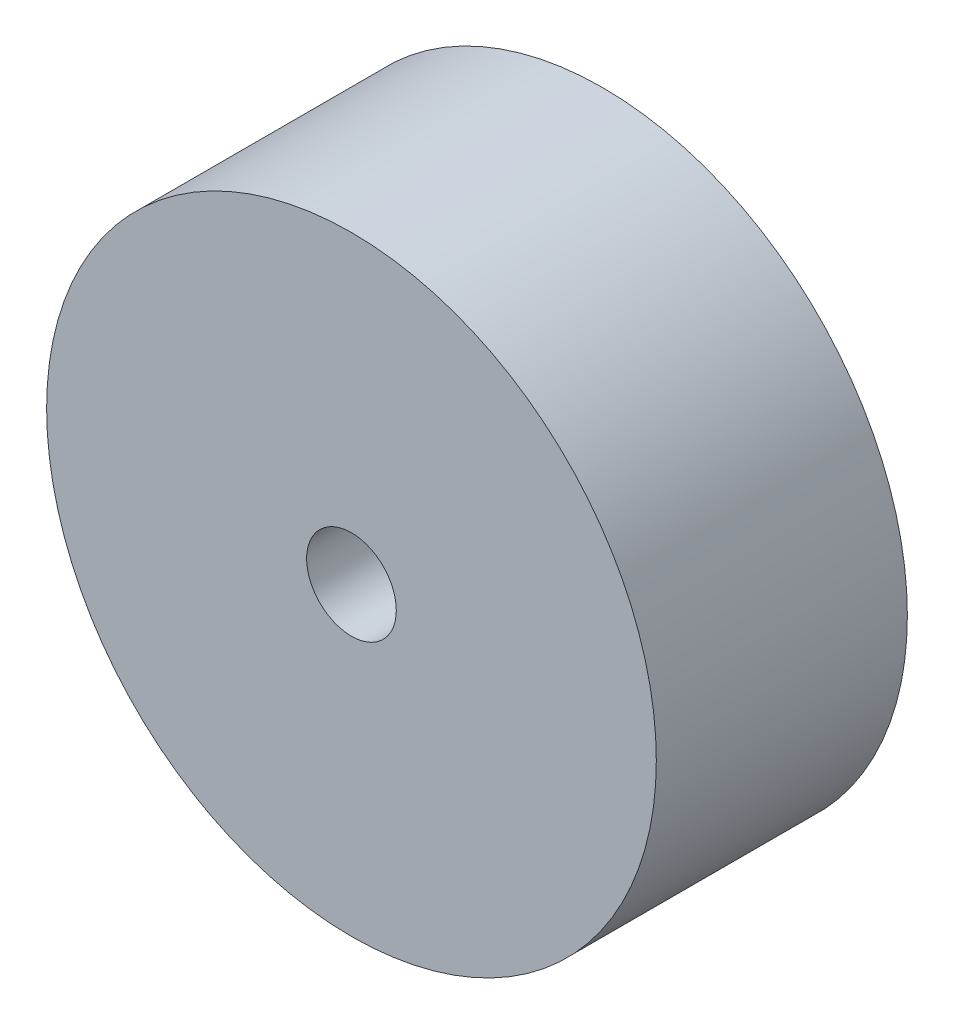
from build123d import *

# Parameters (mm, degrees)
SKETCH_1_R      = 34
SKETCH_1_R_2    = 5
EXTRUDE_1_DEPTH = 28


with BuildPart() as part:
    # 草图1 → 凸台-拉伸1 (new body)
    with BuildSketch(Plane.XY):
        with Locations((-6.783472218, 17.05843749)):
            Circle(SKETCH_1_R)
        with Locations((-6.783472218, 17.05843749)):
            Circle(SKETCH_1_R_2, mode=Mode.SUBTRACT)
    extrude(amount=EXTRUDE_1_DEPTH)


solid = part.part
